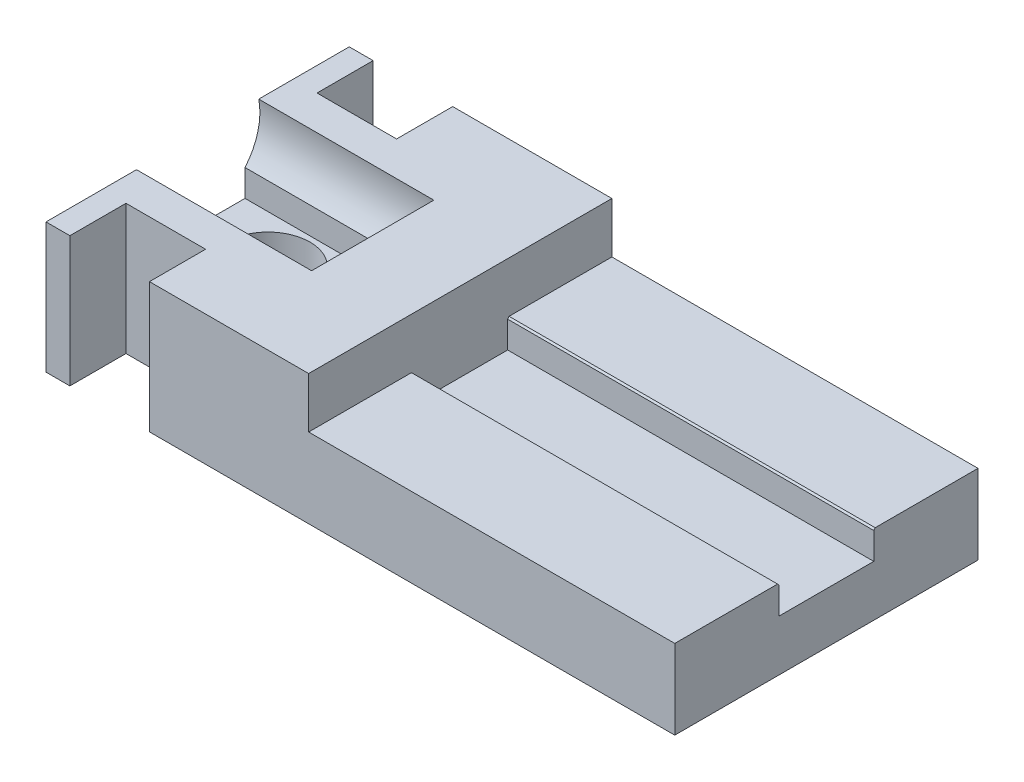
from build123d import *

# Parameters (mm, degrees)
SKETCH5_W                = 33.357089
SKETCH5_H                = 38.1
BOSS_EXTRUDE2_DEPTH      = 1
BOSS_EXTRUDE2_DEPTH_BACK = 78
SKETCH6_W                = 69
SKETCH6_H                = 23.371556831
CUT_EXTRUDE1_DEPTH       = 39.1
SKETCH7_R                = 7.825237577
CUT_EXTRUDE2_DEPTH       = 2
CUT_EXTRUDE2_DEPTH_BACK  = 79
CUT_EXTRUDE3_DEPTH       = 79
SKETCH9_W                = 33
SKETCH9_H                = 38.1
BOSS_EXTRUDE6_DEPTH      = 10
SKETCH11_R               = 7.825237577
CUT_EXTRUDE5_DEPTH       = 79
SKETCH13_W               = 10
SKETCH13_H               = 25.4
CUT_EXTRUDE6_DEPTH       = 11
CUT_EXTRUDE6_DEPTH_BACK  = 7.35
SKETCH14_W               = 11.907690598
SKETCH14_H               = 40
CUT_EXTRUDE8_DEPTH       = 2
CUT_EXTRUDE8_DEPTH_BACK  = 90
SKETCH15_R               = 5.280529318
CUT_EXTRUDE9_DEPTH       = 90
CUT_EXTRUDE9_DEPTH_BACK  = 90
SKETCH16_W               = 38.1
SKETCH16_H               = 16.35
BOSS_EXTRUDE7_DEPTH      = 11


with BuildPart() as part:
    # Sketch5 → Boss-Extrude2 (new body, two sides)
    with BuildSketch(Plane(origin=(0, 0, 0), x_dir=(0, -1, 0), z_dir=(1, 0, 0))) as boss_extrude2_sk:
        with Locations((-10.3285445, 0)):
            Rectangle(SKETCH5_W, SKETCH5_H)
    extrude(amount=BOSS_EXTRUDE2_DEPTH)
    extrude(boss_extrude2_sk.sketch, amount=-BOSS_EXTRUDE2_DEPTH_BACK)

    # Sketch6 → Cut-Extrude1 (cut, through all)
    with BuildSketch(Plane.XY.offset(19.05)):
        with Locations((-33.5, 15.321310585)):
            Rectangle(SKETCH6_W, SKETCH6_H)
    extrude(amount=-CUT_EXTRUDE1_DEPTH, mode=Mode.SUBTRACT)

    # Sketch7 → Cut-Extrude2 (cut, two sides)
    with BuildSketch(Plane(origin=(0, 0, 0), x_dir=(0, 0, -1), z_dir=(1, 0, 0))) as cut_extrude2_sk:
        with Locations((0, 8.496530467)):
            Circle(SKETCH7_R)
    extrude(amount=CUT_EXTRUDE2_DEPTH, mode=Mode.SUBTRACT)
    extrude(cut_extrude2_sk.sketch, amount=-CUT_EXTRUDE2_DEPTH_BACK, mode=Mode.SUBTRACT)

    # Sketch8 → Cut-Extrude3 (cut, through all)
    with BuildSketch(Plane(origin=(0, 0, 0), x_dir=(0, 0, -1), z_dir=(1, 0, 0))):
        with BuildLine():
            Line((-19.05, 3.635532169), (-6.132294733, 3.635532169))
            ThreePointArc((-6.132294733, 3.635532169), (0, 16.321768044), (6.132294733, 3.635532169))
            Line((6.132294733, 3.635532169), (19.05, 3.635532169))
            Line((19.05, 3.635532169), (19.05, 27.007089))
            Line((19.05, 27.007089), (-19.05, 27.007089))
            Line((-19.05, 27.007089), (-19.05, 3.635532169))
        make_face()
        with BuildLine():
            Line((-19.05, 3.635532169), (-6.132294733, 3.635532169))
            ThreePointArc((-6.132294733, 3.635532169), (0, 16.321768044), (6.132294733, 3.635532169))
            Line((6.132294733, 3.635532169), (19.05, 3.635532169))
            Line((19.05, 3.635532169), (19.05, 27.007089))
            Line((19.05, 27.007089), (-19.05, 27.007089))
            Line((-19.05, 27.007089), (-19.05, 3.635532169))
        make_face()
    extrude(amount=-CUT_EXTRUDE3_DEPTH, mode=Mode.SUBTRACT)

    # Sketch9 → Boss-Extrude6 (add)
    with BuildSketch(Plane(origin=(0, 0, 0), x_dir=(1, 0, 0), z_dir=(0, 1, 0))):
        with Locations((-61.5, 0)):
            Rectangle(SKETCH9_W, SKETCH9_H)
    extrude(amount=BOSS_EXTRUDE6_DEPTH)

    # Sketch11 → Cut-Extrude5 (cut, through all)
    with BuildSketch(Plane(origin=(0, 0, 0), x_dir=(0, 0, -1), z_dir=(1, 0, 0))):
        with Locations((0, 8.496530467)):
            Circle(SKETCH11_R)
    extrude(amount=-CUT_EXTRUDE5_DEPTH, mode=Mode.SUBTRACT)

    # Sketch13 → Cut-Extrude6 (cut, two sides)
    with BuildSketch(Plane(origin=(0, 0, 0), x_dir=(1, 0, 0), z_dir=(0, 1, 0))) as cut_extrude6_sk:
        with Locations((-70, -24.7)):
            Rectangle(SKETCH13_W, SKETCH13_H)
        with Locations((-70, 24.7)):
            Rectangle(SKETCH13_W, SKETCH13_H)
    extrude(amount=CUT_EXTRUDE6_DEPTH, mode=Mode.SUBTRACT)
    extrude(cut_extrude6_sk.sketch, amount=-CUT_EXTRUDE6_DEPTH_BACK, mode=Mode.SUBTRACT)

    # Sketch14 → Cut-Extrude8 (cut, two sides)
    with BuildSketch(Plane(origin=(0, 0, 0), x_dir=(0, 0, -1), z_dir=(1, 0, 0))) as cut_extrude8_sk:
        with Locations((0, 20.05843463)):
            Rectangle(SKETCH14_W, SKETCH14_H)
    extrude(amount=CUT_EXTRUDE8_DEPTH, mode=Mode.SUBTRACT)
    extrude(cut_extrude8_sk.sketch, amount=-CUT_EXTRUDE8_DEPTH_BACK, mode=Mode.SUBTRACT)

    # Sketch15 → Cut-Extrude9 (cut, two sides)
    with BuildSketch(Plane(origin=(0, 0, 0), x_dir=(1, 0, 0), z_dir=(0, 1, 0))) as cut_extrude9_sk:
        with Locations((-69.169741906, 0)):
            Circle(SKETCH15_R)
    extrude(amount=CUT_EXTRUDE9_DEPTH, mode=Mode.SUBTRACT)
    extrude(cut_extrude9_sk.sketch, amount=-CUT_EXTRUDE9_DEPTH_BACK, mode=Mode.SUBTRACT)

    # Sketch16 → Boss-Extrude7 (add)
    with BuildSketch(Plane(origin=(-45, 0, 0), x_dir=(0, 0, -1), z_dir=(1, 0, 0))):
        with Locations((0, 1.825)):
            Rectangle(SKETCH16_W, SKETCH16_H)
    extrude(amount=-BOSS_EXTRUDE7_DEPTH)


solid = part.part
